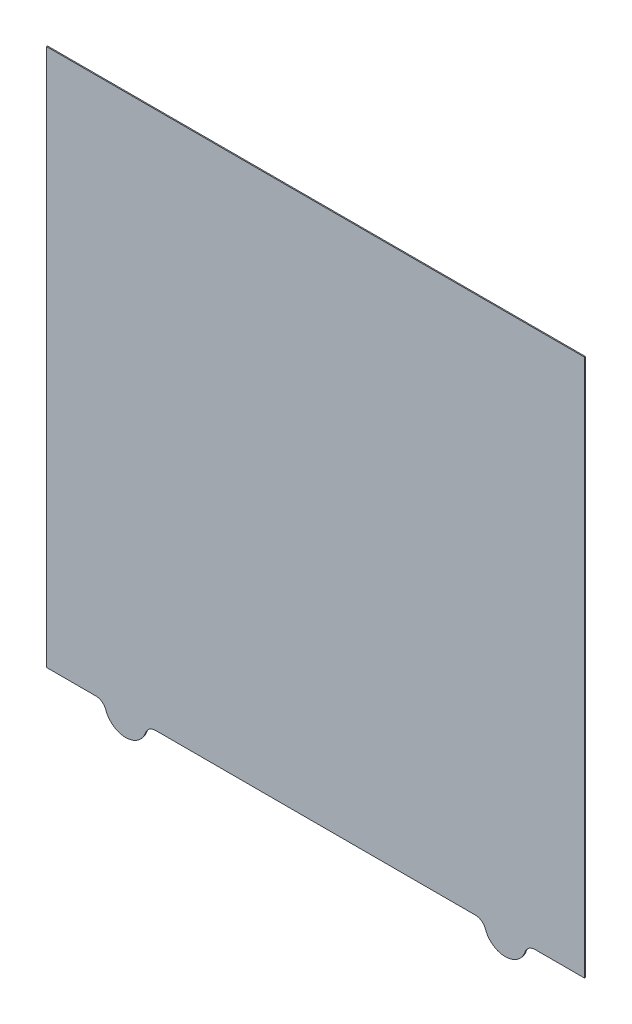
from build123d import *

# Parameters (mm, degrees)
BOSS_EXTRUDE1_DEPTH = 1


with BuildPart() as part:
    # Sketch1 → Boss-Extrude1 (new body)
    with BuildSketch(Plane.XY):
        with BuildLine():
            Line((208.284271247, -255), (255, -255))
            Line((255, -255), (255, 255))
            Line((255, 255), (-255, 255))
            Line((-255, 255), (-255, -255))
            Line((-255, -255), (-208.284271247, -255))
            ThreePointArc((-208.284271247, -255), (-202.510768556, -256.835034191), (-198.856180832, -261.666666667))
            ThreePointArc((-198.856180832, -261.666666667), (-180, -275), (-161.143819168, -261.666666667))
            ThreePointArc((-161.143819168, -261.666666667), (-157.489231444, -256.835034191), (-151.715728753, -255))
            Line((-151.715728753, -255), (151.715728753, -255))
            ThreePointArc((151.715728753, -255), (157.489231444, -256.835034191), (161.143819168, -261.666666667))
            ThreePointArc((161.143819168, -261.666666667), (180, -275), (198.856180832, -261.666666667))
            ThreePointArc((198.856180832, -261.666666667), (202.510768556, -256.835034191), (208.284271247, -255))
        make_face()
    extrude(amount=BOSS_EXTRUDE1_DEPTH)


solid = part.part
